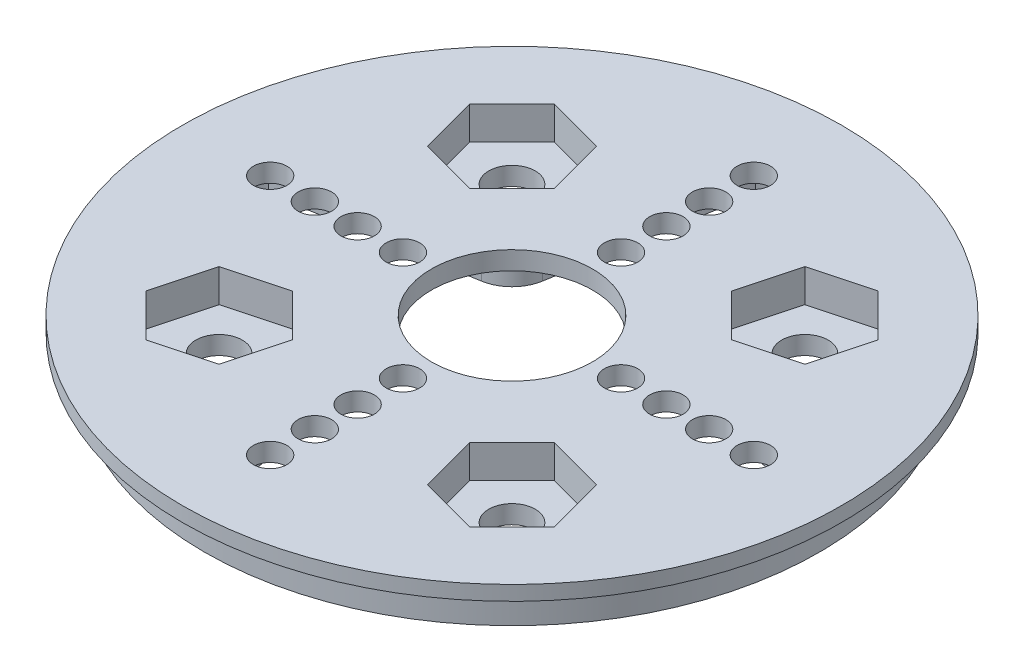
from build123d import *

# Parameters (mm, degrees)
SKETCH2_R           = 21
BOSS_EXTRUDE1_DEPTH = 3.5
CUT_EXTRUDE1_DEPTH  = 2.25
SKETCH4_R           = 5.5
SKETCH4_R_2         = 1.143
SKETCH4_R_3         = 1.5875
CUT_EXTRUDE2_DEPTH  = 4.5
CUT_EXTRUDE4_DEPTH  = 2.25
SKETCH6_W           = 2.148549125
SKETCH6_H           = 1


with BuildPart() as part:
    # Sketch2 → Boss-Extrude1 (new body)
    with BuildSketch(Plane(origin=(0, 0, 0), x_dir=(1, 0, 0), z_dir=(0, 1, 0))):
        Circle(SKETCH2_R)
    extrude(amount=BOSS_EXTRUDE1_DEPTH)

    # Sketch1 → Cut-Extrude1 (cut)
    with BuildSketch(Plane(origin=(0, 0, 0), x_dir=(1, 0, 0), z_dir=(0, 1, 0))):
        with BuildLine():
            Line((-2.382460832, -18.999213313), (-4.483221098, -6.564797513))
            ThreePointArc((-4.483221098, -6.564797513), (-5.191745443, -5.191745443), (-6.564797513, -4.483221098))
            Line((-6.564797513, -4.483221098), (-18.999213313, -2.382460832))
            ThreePointArc((-18.999213313, -2.382460832), (-20, 0), (-18.999213313, 2.382460832))
            Line((-18.999213313, 2.382460832), (-6.564797513, 4.483221098))
            ThreePointArc((-6.564797513, 4.483221098), (-5.191745443, 5.191745443), (-4.483221098, 6.564797513))
            Line((-4.483221098, 6.564797513), (-2.382460832, 18.999213313))
            ThreePointArc((-2.382460832, 18.999213313), (0, 20), (2.382460832, 18.999213313))
            Line((2.382460832, 18.999213313), (4.483221098, 6.564797513))
            ThreePointArc((4.483221098, 6.564797513), (5.191745443, 5.191745443), (6.564797513, 4.483221098))
            Line((6.564797513, 4.483221098), (18.999213313, 2.382460832))
            ThreePointArc((18.999213313, 2.382460832), (20, 0), (18.999213313, -2.382460832))
            Line((18.999213313, -2.382460832), (6.564797513, -4.483221098))
            ThreePointArc((6.564797513, -4.483221098), (5.191745443, -5.191745443), (4.483221098, -6.564797513))
            Line((4.483221098, -6.564797513), (2.382460832, -18.999213313))
            ThreePointArc((2.382460832, -18.999213313), (0, -20), (-2.382460832, -18.999213313))
        make_face()
    extrude(amount=CUT_EXTRUDE1_DEPTH, mode=Mode.SUBTRACT)

    # Sketch4 → Cut-Extrude2 (cut, through all)
    with BuildSketch(Plane(origin=(0, 3.5, 0), x_dir=(1, 0, 0), z_dir=(0, 1, 0))):
        Circle(SKETCH4_R)
        with Locations((7.445, 0)):
            Circle(SKETCH4_R_2)
        with Locations((10.54, 0)):
            Circle(SKETCH4_R_2)
        with Locations((13.46, 0)):
            Circle(SKETCH4_R_2)
        with Locations((16.51, 0)):
            Circle(SKETCH4_R_2)
        with Locations((10, 10)):
            Circle(SKETCH4_R_3)
        with Locations((0, -7.445)):
            Circle(SKETCH4_R_2)
        with Locations((0, -10.54)):
            Circle(SKETCH4_R_2)
        with Locations((0, -13.46)):
            Circle(SKETCH4_R_2)
        with Locations((0, -16.51)):
            Circle(SKETCH4_R_2)
        with Locations((10, -10)):
            Circle(SKETCH4_R_3)
        with Locations((-7.445, 0)):
            Circle(SKETCH4_R_2)
        with Locations((-10.54, 0)):
            Circle(SKETCH4_R_2)
        with Locations((-13.46, 0)):
            Circle(SKETCH4_R_2)
        with Locations((-16.51, 0)):
            Circle(SKETCH4_R_2)
        with Locations((-10, -10)):
            Circle(SKETCH4_R_3)
        with Locations((0, 7.445)):
            Circle(SKETCH4_R_2)
        with Locations((0, 10.54)):
            Circle(SKETCH4_R_2)
        with Locations((0, 13.46)):
            Circle(SKETCH4_R_2)
        with Locations((0, 16.51)):
            Circle(SKETCH4_R_2)
        with Locations((-10, 10)):
            Circle(SKETCH4_R_3)
    extrude(amount=-CUT_EXTRUDE2_DEPTH, mode=Mode.SUBTRACT)

    # Sketch5 → Cut-Extrude4 (cut)
    with BuildSketch(Plane(origin=(0, 3.5, 0), x_dir=(1, 0, 0), z_dir=(0, 1, 0))):
        Polygon((11.055981704, -13.940977371), (13.940977371, -11.055981704), (12.884995667, -7.115004333), (8.944018296, -6.059022629), (6.059022629, -8.944018296), (7.115004333, -12.884995667), align=None)
        Polygon((-8.944018296, 6.059022629), (-6.059022629, 8.944018296), (-7.115004333, 12.884995667), (-11.055981704, 13.940977371), (-13.940977371, 11.055981704), (-12.884995667, 7.115004333), align=None)
        Polygon((12.884995667, 7.115004333), (13.940977371, 11.055981704), (11.055981704, 13.940977371), (7.115004333, 12.884995667), (6.059022629, 8.944018296), (8.944018296, 6.059022629), align=None)
        Polygon((-7.115004333, -12.884995667), (-6.059022629, -8.944018296), (-8.944018296, -6.059022629), (-12.884995667, -7.115004333), (-13.940977371, -11.055981704), (-11.055981704, -13.940977371), align=None)
    extrude(amount=-CUT_EXTRUDE4_DEPTH, mode=Mode.SUBTRACT)

    # Sketch6 → Revolve1 (revolve)
    with BuildSketch(Plane.XY):
        with Locations((-21.425725437, 3)):
            Rectangle(SKETCH6_W, SKETCH6_H)
    revolve(axis=Axis((0, 0, 0), (0, 1, 0)))


solid = part.part
